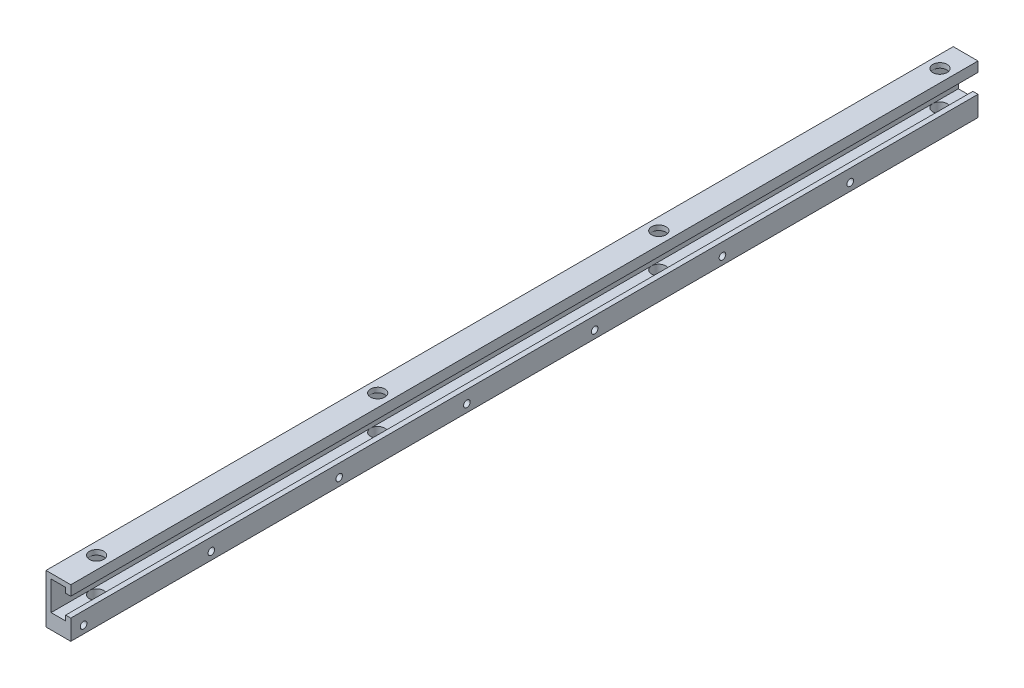
from build123d import *

# Parameters (mm, degrees)
EXTRUDE_1_DEPTH          = 355
CUT_EXTRUDE_1_DEPTH      = 356.321896314
CUT_EXTRUDE_1_DEPTH_BACK = 356.321896314
SKETCH_2_R               = 1.3
CUT_EXTRUDE_2_DEPTH      = 356.321896314
CUT_EXTRUDE_2_DEPTH_BACK = 4
SKETCH_2_3_R             = 2.8
SKETCH_2_3_R_2           = 1.3
SKETCH_13_R              = 2.8
SKETCH_13_R_2            = 1.6
CUT_EXTRUDE_11_DEPTH     = 17
SKETCH_13_4_R            = 1.6
CUT_EXTRUDE_12_DEPTH     = 356.58195961


with BuildPart() as part:
    # 草图1 → 凸台-拉伸1 (new body)
    with BuildSketch(Plane.XY):
        Polygon((-3, 0), (-3, 5.6), (-3, 7.6), (2.6, 7.6), (6.7, 7.6), (6.7, 3.7), (4.7, 3.7), (4.7, 5.7), (-1, 5.7), (-1, 0), (-1, -5.7), (4.7, -5.7), (4.7, -3.7), (6.7, -3.7), (6.7, -7.6), (6.7, -11.6), (-3, -11.6), (-3, -7.6), (-3, -5.6), align=None)
    extrude(amount=EXTRUDE_1_DEPTH)

    # 草图2 → 切除-拉伸1 (cut, two sides: drawn at the far end of the back side and taken through both)
    with BuildSketch(Plane.ZY.offset(3).offset(-CUT_EXTRUDE_1_DEPTH_BACK)):
        with Locations((150, -8.6)):
            Circle(SKETCH_2_R)
        with Locations((100, -8.6)):
            Circle(SKETCH_2_R)
        with Locations((50, -8.6)):
            Circle(SKETCH_2_R)
        with Locations((200, -8.6)):
            Circle(SKETCH_2_R)
        with Locations((250, -8.6)):
            Circle(SKETCH_2_R)
        with Locations((300, -8.6)):
            Circle(SKETCH_2_R)
        with Locations((350, -8.6)):
            Circle(SKETCH_2_R)
    extrude(amount=CUT_EXTRUDE_1_DEPTH + CUT_EXTRUDE_1_DEPTH_BACK, mode=Mode.SUBTRACT)

    # 草图2<3> → 切除-拉伸2 (cut, two sides: drawn at the far end of the back side and taken through both)
    # profile 1 of 7: a face of its own
    with BuildSketch(Plane.ZY.offset(3).offset(-CUT_EXTRUDE_2_DEPTH_BACK)):
        with Locations((200, -8.6)):
            Circle(SKETCH_2_3_R)
        with Locations((200, -8.6)):
            Circle(SKETCH_2_3_R_2, mode=Mode.SUBTRACT)
    # profile 2 of 7: a face of its own
    with BuildSketch(Plane.ZY.offset(3).offset(-CUT_EXTRUDE_2_DEPTH_BACK)):
        with Locations((250, -8.6)):
            Circle(SKETCH_2_3_R)
        with Locations((250, -8.6)):
            Circle(SKETCH_2_3_R_2, mode=Mode.SUBTRACT)
    # profile 3 of 7: a face of its own
    with BuildSketch(Plane.ZY.offset(3).offset(-CUT_EXTRUDE_2_DEPTH_BACK)):
        with Locations((150, -8.6)):
            Circle(SKETCH_2_3_R)
        with Locations((150, -8.6)):
            Circle(SKETCH_2_3_R_2, mode=Mode.SUBTRACT)
    # profile 4 of 7: a face of its own
    with BuildSketch(Plane.ZY.offset(3).offset(-CUT_EXTRUDE_2_DEPTH_BACK)):
        with Locations((100, -8.6)):
            Circle(SKETCH_2_3_R)
        with Locations((100, -8.6)):
            Circle(SKETCH_2_3_R_2, mode=Mode.SUBTRACT)
    # profile 5 of 7: a face of its own
    with BuildSketch(Plane.ZY.offset(3).offset(-CUT_EXTRUDE_2_DEPTH_BACK)):
        with Locations((50, -8.6)):
            Circle(SKETCH_2_3_R)
        with Locations((50, -8.6)):
            Circle(SKETCH_2_3_R_2, mode=Mode.SUBTRACT)
    # profile 6 of 7: a face of its own
    with BuildSketch(Plane.ZY.offset(3).offset(-CUT_EXTRUDE_2_DEPTH_BACK)):
        with Locations((300, -8.6)):
            Circle(SKETCH_2_3_R)
        with Locations((300, -8.6)):
            Circle(SKETCH_2_3_R_2, mode=Mode.SUBTRACT)
    # profile 7 of 7: a face of its own
    with BuildSketch(Plane.ZY.offset(3).offset(-CUT_EXTRUDE_2_DEPTH_BACK)):
        with Locations((350, -8.6)):
            Circle(SKETCH_2_3_R)
        with Locations((350, -8.6)):
            Circle(SKETCH_2_3_R_2, mode=Mode.SUBTRACT)
    extrude(amount=CUT_EXTRUDE_2_DEPTH + CUT_EXTRUDE_2_DEPTH_BACK, mode=Mode.SUBTRACT)

    # 草图13 → 切除-拉伸11 (cut)
    # profile 1 of 4: a face of its own
    with BuildSketch(Plane(origin=(0, 7.6, 0), x_dir=(1, 0, 0), z_dir=(0, 1, 0))):
        with Locations((1.8, -10)):
            Circle(SKETCH_13_R)
        with Locations((1.8, -10)):
            Circle(SKETCH_13_R_2, mode=Mode.SUBTRACT)
    # profile 2 of 4: a face of its own
    with BuildSketch(Plane(origin=(0, 7.6, 0), x_dir=(1, 0, 0), z_dir=(0, 1, 0))):
        with Locations((1.8, -120)):
            Circle(SKETCH_13_R)
        with Locations((1.8, -120)):
            Circle(SKETCH_13_R_2, mode=Mode.SUBTRACT)
    # profile 3 of 4: a face of its own
    with BuildSketch(Plane(origin=(0, 7.6, 0), x_dir=(1, 0, 0), z_dir=(0, 1, 0))):
        with Locations((1.8, -340)):
            Circle(SKETCH_13_R)
        with Locations((1.8, -340)):
            Circle(SKETCH_13_R_2, mode=Mode.SUBTRACT)
    # profile 4 of 4: a face of its own
    with BuildSketch(Plane(origin=(0, 7.6, 0), x_dir=(1, 0, 0), z_dir=(0, 1, 0))):
        with Locations((1.8, -230)):
            Circle(SKETCH_13_R)
        with Locations((1.8, -230)):
            Circle(SKETCH_13_R_2, mode=Mode.SUBTRACT)
    extrude(amount=-CUT_EXTRUDE_11_DEPTH, mode=Mode.SUBTRACT)


with BuildPart() as cut_extrude_11_piece_1:
    # of the separate pieces the step leaves, piece 1, a body of its own (cut_extrude_11_pieces)
    add(part.part.solids().sort_by_distance((-3, -11.6, 0))[0])


with BuildPart() as cut_extrude_11_piece_2:
    # of the separate pieces the step leaves, piece 2, a body of its own (cut_extrude_11_pieces)
    add(part.part.solids().sort_by_distance((3.4, 7.6, 120))[0])


with BuildPart() as cut_extrude_11_piece_3:
    # of the separate pieces the step leaves, piece 3, a body of its own (cut_extrude_11_pieces)
    add(part.part.solids().sort_by_distance((3.4, 7.6, 10))[0])


with BuildPart() as cut_extrude_11_piece_4:
    # of the separate pieces the step leaves, piece 4, a body of its own (cut_extrude_11_pieces)
    add(part.part.solids().sort_by_distance((3.4, 7.6, 340))[0])


with BuildPart() as cut_extrude_11_piece_5:
    # of the separate pieces the step leaves, piece 5, a body of its own (cut_extrude_11_pieces)
    add(part.part.solids().sort_by_distance((3.4, 7.6, 230))[0])


with BuildPart() as cut_extrude_12_tool:
    # 草图13<4> → 切除-拉伸12 (new, through all)
    with BuildSketch(Plane(origin=(0, 7.6, 0), x_dir=(1, 0, 0), z_dir=(0, 1, 0))):
        with Locations((1.8, -10)):
            Circle(SKETCH_13_4_R)
        with Locations((1.8, -120)):
            Circle(SKETCH_13_4_R)
        with Locations((1.8, -340)):
            Circle(SKETCH_13_4_R)
        with Locations((1.8, -230)):
            Circle(SKETCH_13_4_R)
    extrude(amount=-CUT_EXTRUDE_12_DEPTH)


with BuildPart() as cut_extrude_11_piece_1_1:
    add(cut_extrude_11_piece_1.part)

    # 切除-拉伸12: cut by cut_extrude_12_tool
    add(cut_extrude_12_tool.part, mode=Mode.SUBTRACT)


with BuildPart() as cut_extrude_11_piece_2_1:
    add(cut_extrude_11_piece_2.part)

    # 切除-拉伸12: cut by cut_extrude_12_tool
    add(cut_extrude_12_tool.part, mode=Mode.SUBTRACT)


with BuildPart() as cut_extrude_11_piece_3_1:
    add(cut_extrude_11_piece_3.part)

    # 切除-拉伸12: cut by cut_extrude_12_tool
    add(cut_extrude_12_tool.part, mode=Mode.SUBTRACT)


with BuildPart() as cut_extrude_11_piece_4_1:
    add(cut_extrude_11_piece_4.part)

    # 切除-拉伸12: cut by cut_extrude_12_tool
    add(cut_extrude_12_tool.part, mode=Mode.SUBTRACT)


with BuildPart() as cut_extrude_11_piece_5_1:
    add(cut_extrude_11_piece_5.part)

    # 切除-拉伸12: cut by cut_extrude_12_tool
    add(cut_extrude_12_tool.part, mode=Mode.SUBTRACT)


solid = cut_extrude_11_piece_1_1.part
